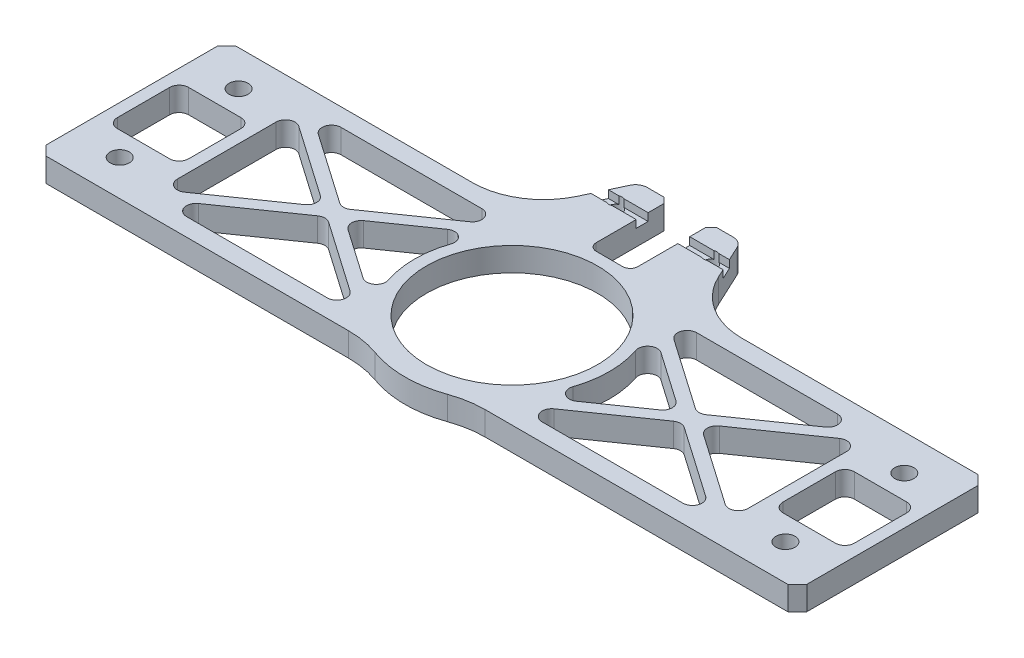
from build123d import *

# Parameters (mm, degrees)
BOSS_EXTRUDE1_DEPTH        = 6.35
F_10_CLEARANCE_HOLE1_D     = 5.1054
F_10_CLEARANCE_HOLE1_DEPTH = 6.35
SKETCH5_R                  = 22.86
CUT_EXTRUDE1_DEPTH         = 7.35
CHAMFER1_SIZE              = 2.54
SKETCH6_W                  = 19.05
SKETCH6_H                  = 19.05
CUT_EXTRUDE2_DEPTH         = 6.35
FILLET1_R                  = 2.54
BOSS_EXTRUDE2_DEPTH        = 6.35
SKETCH8_W                  = 35.278450162
SKETCH8_H                  = 3.175
CUT_EXTRUDE3_DEPTH         = 2.032
CUT_EXTRUDE4_DEPTH         = 7.35
F_8_32_TAPPED_HOLE1_D      = 3.4544
F_8_32_TAPPED_HOLE1_DEPTH  = 6.35


with BuildPart() as part:
    # Sketch1 → Boss-Extrude1 (new body)
    with BuildSketch(Plane(origin=(0, 0, 0), x_dir=(1, 0, 0), z_dir=(0, 1, 0))):
        with BuildLine():
            Line((0, 0), (83.361013597, 0))
            ThreePointArc((83.361013597, 0), (87.71707766, -0.3763171), (91.944066022, -1.494117647))
            ThreePointArc((91.944066022, -1.494117647), (101.6, -3.175), (111.255933978, -1.494117647))
            ThreePointArc((111.255933978, -1.494117647), (115.48292234, -0.3763171), (119.838986403, 0))
            Line((119.838986403, 0), (203.2, 0))
            Line((203.2, 0), (203.2, 50.8))
            Line((203.2, 50.8), (119.838986403, 50.8))
            ThreePointArc((119.838986403, 50.8), (115.48292234, 51.1763171), (111.255933978, 52.294117647))
            ThreePointArc((111.255933978, 52.294117647), (101.6, 53.975), (91.944066022, 52.294117647))
            ThreePointArc((91.944066022, 52.294117647), (87.71707766, 51.1763171), (83.361013597, 50.8))
            Line((83.361013597, 50.8), (0, 50.8))
            Line((0, 50.8), (0, 0))
        make_face()
    extrude(amount=BOSS_EXTRUDE1_DEPTH)

    # #10 Clearance Hole1
    with Locations(Plane(origin=(0, 6.35, 0), x_dir=(1, 0, 0), z_dir=(0, 1, 0))):
        with Locations((12.7, 41.275), (12.7, 9.525), (190.5, 9.525), (190.5, 41.275)):
            Hole(F_10_CLEARANCE_HOLE1_D / 2, depth=F_10_CLEARANCE_HOLE1_DEPTH)

    # Sketch5 → Cut-Extrude1 (cut, through all)
    with BuildSketch(Plane(origin=(0, 6.35, 0), x_dir=(1, 0, 0), z_dir=(0, 1, 0))):
        with Locations((101.6, 25.4)):
            Circle(SKETCH5_R)
    extrude(amount=-CUT_EXTRUDE1_DEPTH, mode=Mode.SUBTRACT)

    # Chamfer1
    chamfer1_edges = [part.edges().sort_by_distance(p)[0] for p in [
        (0, 3.175, -50.8),
        (203.2, 3.175, -50.8),
        (203.2, 3.175, 0),
        (0, 3.175, 0),
    ]]
    chamfer(chamfer1_edges, length=CHAMFER1_SIZE)

    # Sketch6 → Cut-Extrude2 (cut)
    with BuildSketch(Plane(origin=(0, 6.35, 0), x_dir=(1, 0, 0), z_dir=(0, 1, 0))):
        Polygon((27.212667469, 46.0375), (81.006722435, 46.0375), (54.109694952, 27.333602302), align=None)
        Polygon((25.4, 43.430804459), (25.4, 7.369195541), (51.329089802, 25.4), align=None)
        Polygon((27.212667469, 4.7625), (81.006722435, 4.7625), (54.109694952, 23.466397698), align=None)
        with Locations((12.7, 25.4)):
            Rectangle(SKETCH6_W, SKETCH6_H)
        with BuildLine():
            Line((56.890300102, 25.4), (82.819389904, 43.430804459))
            ThreePointArc((82.819389904, 43.430804459), (75.565, 25.4), (82.819389904, 7.369195541))
            Line((82.819389904, 7.369195541), (56.890300102, 25.4))
        make_face()
        Polygon((151.870910198, 25.4), (177.8, 43.430804459), (177.8, 7.369195541), align=None)
        with BuildLine():
            Line((146.309699898, 25.4), (120.380610096, 7.369195541))
            ThreePointArc((120.380610096, 7.369195541), (127.635, 25.4), (120.380610096, 43.430804459))
            Line((120.380610096, 43.430804459), (146.309699898, 25.4))
        make_face()
        Polygon((175.987332531, 4.7625), (149.090305048, 23.466397698), (122.193277565, 4.7625), align=None)
        Polygon((122.193277565, 46.0375), (149.090305048, 27.333602302), (175.987332531, 46.0375), align=None)
        with Locations((190.5, 25.4)):
            Rectangle(SKETCH6_W, SKETCH6_H)
    extrude(amount=-CUT_EXTRUDE2_DEPTH, mode=Mode.SUBTRACT)

    # Fillet1
    fillet1_edges = [part.edges().sort_by_distance(p)[0] for p in [
        (180.975, 3.175, -34.925),
        (200.025, 3.175, -34.925),
        (200.025, 3.175, -15.875),
        (180.975, 3.175, -15.875),
        (120.380610096, 3.175, -7.369195541),
        (120.380610096, 3.175, -43.430804459),
        (146.309699898, 3.175, -25.4),
        (51.329089802, 3.175, -25.4),
        (25.4, 3.175, -7.369195541),
        (25.4, 3.175, -43.430804459),
        (82.819389904, 3.175, -43.430804459),
        (82.819389904, 3.175, -7.369195541),
        (56.890300102, 3.175, -25.4),
        (54.109694952, 3.175, -23.466397698),
        (81.006722435, 3.175, -4.7625),
        (27.212667469, 3.175, -4.7625),
        (3.175, 3.175, -15.875),
        (3.175, 3.175, -34.925),
        (22.225, 3.175, -34.925),
        (22.225, 3.175, -15.875),
        (122.193277565, 3.175, -46.0375),
        (175.987332531, 3.175, -46.0375),
        (149.090305048, 3.175, -27.333602302),
        (177.8, 3.175, -7.369195541),
        (151.870910198, 3.175, -25.4),
        (177.8, 3.175, -43.430804459),
        (175.987332531, 3.175, -4.7625),
        (122.193277565, 3.175, -4.7625),
        (149.090305048, 3.175, -23.466397698),
        (81.006722435, 3.175, -46.0375),
        (54.109694952, 3.175, -27.333602302),
        (27.212667469, 3.175, -46.0375),
    ]]
    fillet(fillet1_edges, radius=FILLET1_R)

    # Sketch7 → Boss-Extrude2 (add)
    with BuildSketch(Plane(origin=(0, 0, 0), x_dir=(1, 0, 0), z_dir=(0, 1, 0))):
        with BuildLine():
            Line((82.871537172, 61.799122114), (87.251420854, 71.191812981))
            ThreePointArc((87.251420854, 71.191812981), (88.423021822, 72.52776784), (90.128948078, 73.025))
            Line((90.128948078, 73.025), (94.51975, 73.025))
            Line((94.51975, 73.025), (96.04375, 71.501))
            Line((96.04375, 71.501), (96.04375, 53.429604188))
            ThreePointArc((96.04375, 53.429604188), (93.972748348, 52.938258065), (91.944066022, 52.294117647))
            ThreePointArc((91.944066022, 52.294117647), (87.71707766, 51.1763171), (83.361013597, 50.8))
            Line((83.361013597, 50.8), (65.606373829, 50.8))
            ThreePointArc((65.606373829, 50.8), (75.841931368, 53.783392957), (82.871537172, 61.799122114))
        make_face()
        with BuildLine():
            Line((120.328462828, 61.799122114), (115.948579146, 71.191812981))
            ThreePointArc((115.948579146, 71.191812981), (114.776978178, 72.52776784), (113.071051922, 73.025))
            Line((113.071051922, 73.025), (108.68025, 73.025))
            Line((108.68025, 73.025), (107.15625, 71.501))
            Line((107.15625, 71.501), (107.15625, 53.429604188))
            ThreePointArc((107.15625, 53.429604188), (109.227251652, 52.938258065), (111.255933978, 52.294117647))
            ThreePointArc((111.255933978, 52.294117647), (115.48292234, 51.1763171), (119.838986403, 50.8))
            Line((119.838986403, 50.8), (137.593626171, 50.8))
            ThreePointArc((137.593626171, 50.8), (127.358068632, 53.783392957), (120.328462828, 61.799122114))
        make_face()
    extrude(amount=BOSS_EXTRUDE2_DEPTH)

    # Sketch8 → Cut-Extrude3 (cut)
    with BuildSketch(Plane(origin=(0, 6.35, 0), x_dir=(1, 0, 0), z_dir=(0, 1, 0))):
        with Locations((101.6, 65.7225)):
            Rectangle(SKETCH8_W, SKETCH8_H)
    extrude(amount=-CUT_EXTRUDE3_DEPTH, mode=Mode.SUBTRACT)

    # Sketch9 → Cut-Extrude4 (cut, through all)
    with BuildSketch(Plane(origin=(0, 6.35, 0), x_dir=(1, 0, 0), z_dir=(0, 1, 0))):
        with BuildLine():
            Line((96.04375, 73.025), (107.15625, 73.025))
            Line((107.15625, 73.025), (107.15625, 53.467))
            ThreePointArc((107.15625, 53.467), (106.561090979, 52.030159021), (105.12425, 51.435))
            Line((105.12425, 51.435), (98.07575, 51.435))
            ThreePointArc((98.07575, 51.435), (96.638909021, 52.030159021), (96.04375, 53.467))
            Line((96.04375, 53.467), (96.04375, 73.025))
        make_face()
    extrude(amount=-CUT_EXTRUDE4_DEPTH, mode=Mode.SUBTRACT)

    # #8-32 Tapped Hole1
    with Locations(Plane(origin=(0, 6.35, 0), x_dir=(1, 0, 0), z_dir=(0, 1, 0))):
        with Locations((88.9, 65.7225), (114.3, 65.7225)):
            Hole(F_8_32_TAPPED_HOLE1_D / 2, depth=F_8_32_TAPPED_HOLE1_DEPTH)


solid = part.part
